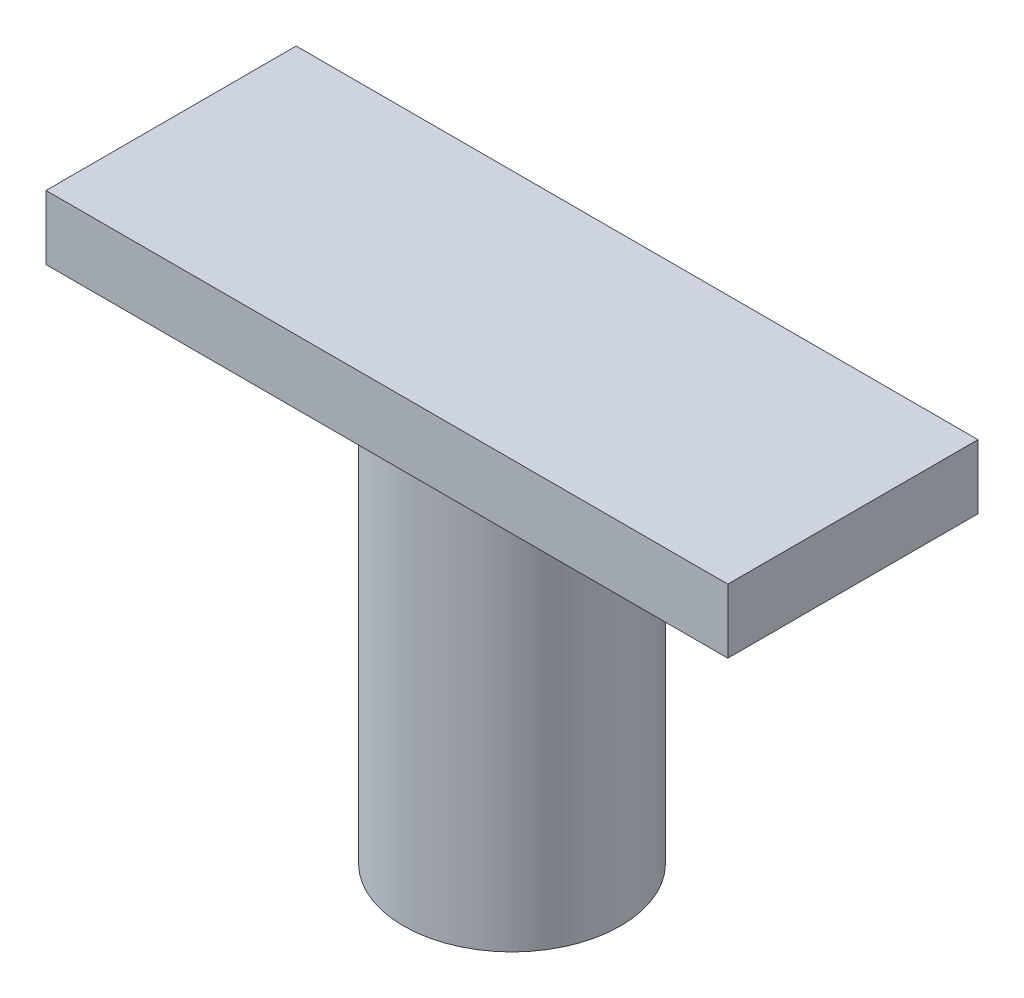
from build123d import *

# Parameters (mm, degrees)
SKETCH1_R           = 16.916621232
BOSS_EXTRUDE1_DEPTH = 64
SKETCH2_W           = 106.262974488
SKETCH2_H           = 38.987679284
BOSS_EXTRUDE2_DEPTH = 10


with BuildPart() as part:
    # Sketch1 → Boss-Extrude1 (new body)
    with BuildSketch(Plane(origin=(0, 0, 0), x_dir=(1, 0, 0), z_dir=(0, 1, 0))):
        with Locations((22.72979363, -8.239550191)):
            Circle(SKETCH1_R)
    extrude(amount=BOSS_EXTRUDE1_DEPTH)

    # Sketch2 → Boss-Extrude2 (add)
    with BuildSketch(Plane(origin=(0, 64, 0), x_dir=(1, 0, 0), z_dir=(0, 1, 0))):
        with Locations((22.72979363, -8.239550191)):
            Rectangle(SKETCH2_W, SKETCH2_H)
    extrude(amount=BOSS_EXTRUDE2_DEPTH)


solid = part.part
